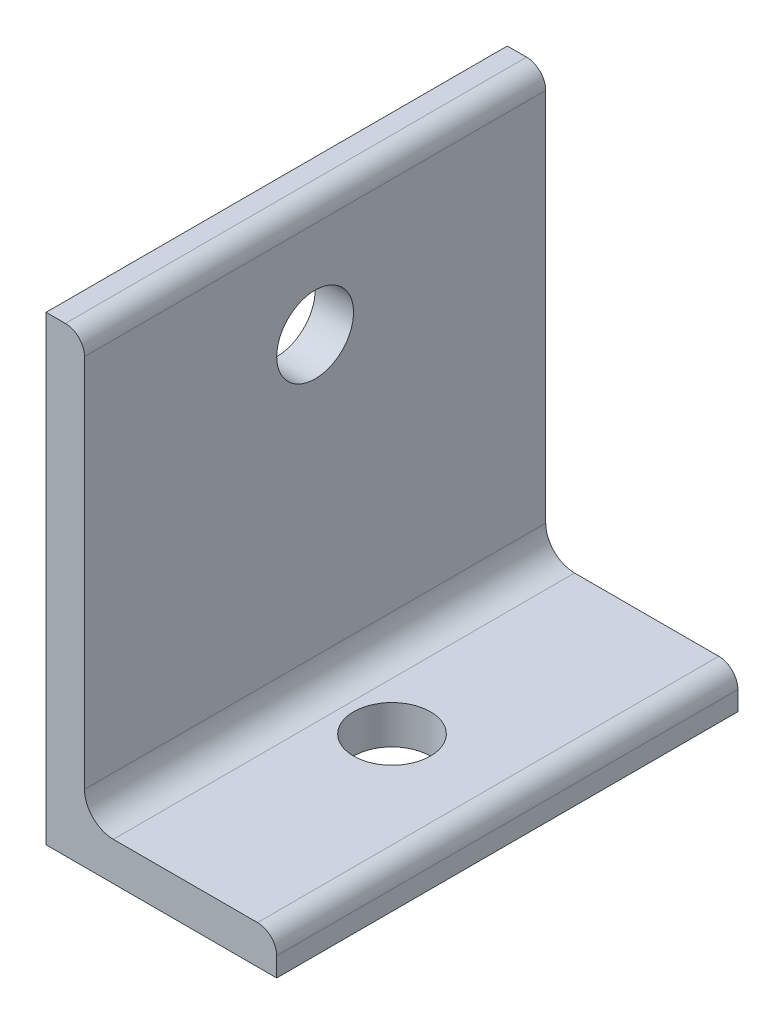
from build123d import *

# Parameters (mm, degrees)
BASESTEELANGLE_DEPTH = 38.1
CUT_EXTRUDE1_REACH   = 78.2
SKETCH2_R            = 6.35
SKETCH3_R            = 6.35
CUT_EXTRUDE2_DEPTH   = 39.1


with BuildPart() as part:
    # Sketch1 → BaseSteelAngle (new body, symmetric)
    with BuildSketch(Plane.XY):
        with BuildLine():
            Line((0, 0), (0, 76.2))
            Line((0, 76.2), (3.18008, 76.2))
            ThreePointArc((3.18008, 76.2), (5.421551928, 75.271551928), (6.35, 73.03008))
            Line((6.35, 73.03008), (6.35, 11.1125))
            ThreePointArc((6.35, 11.1125), (7.744903955, 7.744903955), (11.1125, 6.35))
            Line((11.1125, 6.35), (34.93008, 6.35))
            ThreePointArc((34.93008, 6.35), (37.171551928, 5.421551928), (38.1, 3.18008))
            Line((38.1, 3.18008), (38.1, 0))
            Line((38.1, 0), (0, 0))
        make_face()
    extrude(amount=BASESTEELANGLE_DEPTH, both=True)

    # Sketch2 → Cut-Extrude1 (cut, up to next)
    with BuildSketch(Plane.XZ, mode=Mode.PRIVATE) as cut_extrude1_sk1:
        with Locations((19.05, 0)):
            Circle(SKETCH2_R)
    cut_extrude1_tool1 = extrude(cut_extrude1_sk1.sketch, amount=-CUT_EXTRUDE1_REACH, mode=Mode.PRIVATE) & part.part
    add(cut_extrude1_tool1.solids().sort_by_distance((19.05, 0, 0))[0], mode=Mode.SUBTRACT)

    # Sketch3 → Cut-Extrude2 (cut, through all)
    with BuildSketch(Plane.ZY):
        with Locations((0, 57.15)):
            Circle(SKETCH3_R)
    extrude(amount=-CUT_EXTRUDE2_DEPTH, mode=Mode.SUBTRACT)


solid = part.part
